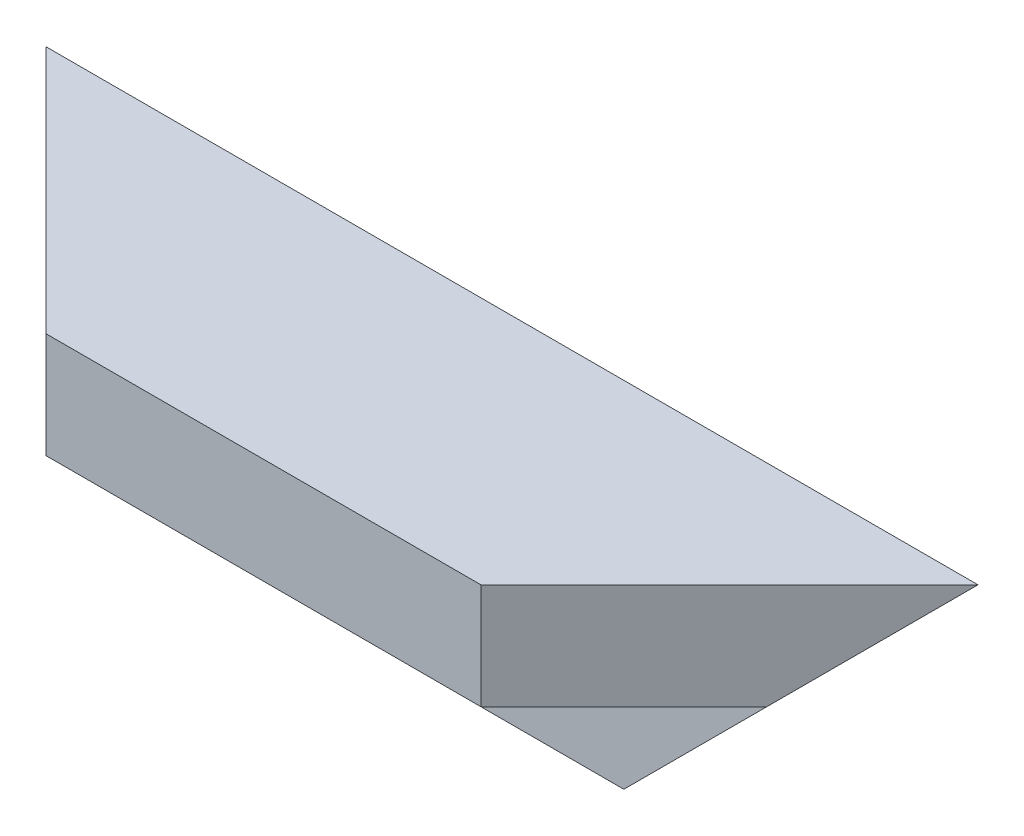
from build123d import *

# Parameters (mm, degrees)
BOSS_EXTRU_1_DEPTH      = 150
ENL_V_MAT_EXTRU_1_DEPTH = 41
ENL_V_MAT_EXTRU_2_DEPTH = 41


with BuildPart() as part:
    # Esquisse1 → Boss.-Extru.1 (new body)
    with BuildSketch(Plane(origin=(0, 0, 0), x_dir=(0, 0, -1), z_dir=(1, 0, 0))):
        Polygon((0, 0), (-40, 0), (-40, -17), (-17, -17), (-17, -40), (0, -40), align=None)
    extrude(amount=BOSS_EXTRU_1_DEPTH)

    # Esquisse2 → Enlèv. mat.-Extru.1 (cut, through all)
    with BuildSketch(Plane(origin=(0, 0, 0), x_dir=(1, 0, 0), z_dir=(0, 1, 0))):
        Polygon((150, 0), (110, -40), (150, -40), align=None)
        Polygon((0, 0), (0, -40), (40, -40), align=None)
    extrude(amount=-ENL_V_MAT_EXTRU_1_DEPTH, mode=Mode.SUBTRACT)

    # Esquisse3 → Enlèv. mat.-Extru.2 (cut, through all)
    with BuildSketch(Plane(origin=(0, 0, 0), x_dir=(-1, 0, 0), z_dir=(0, 0, -1))):
        Polygon((-150, 0), (-110, -40), (-150, -40), align=None)
        Polygon((-40, -40), (0, -40), (0, 0), align=None)
    extrude(amount=-ENL_V_MAT_EXTRU_2_DEPTH, mode=Mode.SUBTRACT)


solid = part.part
